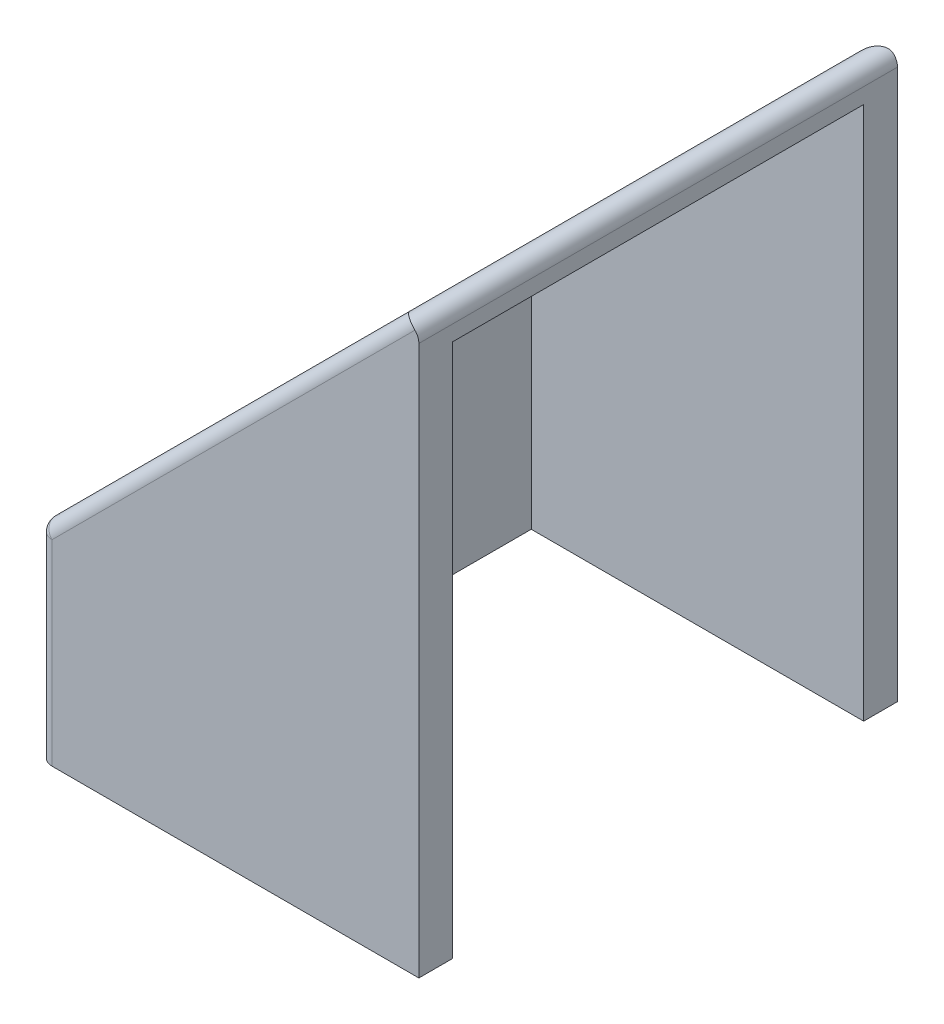
from build123d import *

# Parameters (mm, degrees)
BOSS_EXTRUDE1_DEPTH              = 22.606
CUT_EXTRUDE1_REACH               = 21.561
CUT_EXTRUDE1_OFFSET_FROM_SURFACE = 1.6
SKETCH2_W                        = 19.406
SKETCH2_H                        = 16.360512242
BOSS_EXTRUDE2_DEPTH              = 9.525
FILLET1_R                        = 0.635


with BuildPart() as part:
    # Sketch1 → Boss-Extrude1 (new body)
    with BuildSketch(Plane.XY):
        Polygon((0, 0), (17.960512242, 17.960512242), (17.960512242, 0), align=None)
    extrude(amount=BOSS_EXTRUDE1_DEPTH)

    # Cut-Extrude1: up to this face of the body (flat: up to its plane, moved by the offset)
    cut_extrude1_end = Plane(part.part.faces().sort_by_distance((8.980256121, 8.980256121, 11.303))[0]).offset(-CUT_EXTRUDE1_OFFSET_FROM_SURFACE)
    # Sketch2 → Cut-Extrude1 (cut, up to the picked face)
    with BuildSketch(Plane(origin=(17.960512242, 0, 0), x_dir=(0, 0, -1), z_dir=(1, 0, 0)), mode=Mode.PRIVATE) as cut_extrude1_sk1:
        with Locations((-11.303, 8.180256121)):
            Rectangle(SKETCH2_W, SKETCH2_H)
    cut_extrude1_tool1 = split(extrude(cut_extrude1_sk1.sketch, amount=-CUT_EXTRUDE1_REACH, mode=Mode.PRIVATE), bisect_by=cut_extrude1_end, keep=Keep.BOTH, mode=Mode.PRIVATE)
    add(cut_extrude1_tool1.solids().sort_by_distance((17.960512, 8.180256, 11.303))[0], mode=Mode.SUBTRACT)

    # Sketch3 → Boss-Extrude2 (add)
    with BuildSketch(Plane.XZ):
        Polygon((17.960512242, 22.606), (0, 22.606), (0, 0), (17.960512242, 0), (17.960512242, 1.6), (2.2627417, 1.6), (2.2627417, 21.006), (17.960512242, 21.006), align=None)
    extrude(amount=BOSS_EXTRUDE2_DEPTH)

    # Fillet1
    fillet1_edges = [part.edges().sort_by_distance(p)[0] for p in [
        (8.980256121, 8.980256121, 22.606),
        (0, -4.7625, 22.606),
        (0, -4.7625, 0),
        (8.980256121, 8.980256121, 0),
        (0, 0, 11.303),
        (17.960512242, 17.960512242, 11.303),
    ]]
    fillet(fillet1_edges, radius=FILLET1_R)


solid = part.part
